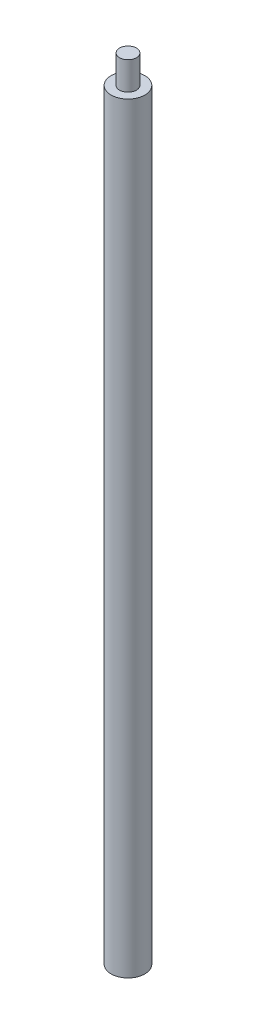
from build123d import *

# Parameters (mm, degrees)
ESBO_O1_R                     = 3
RESSALTO_EXTRUS_O1_DEPTH      = 135.5
FURO_ROSCADO_DE_M3X0_51_D     = 2.5
FURO_ROSCADO_DE_M3X0_51_DEPTH = 18.5
FURO_ROSCADO_DE_M3X0_51_TIP   = 0.751075774
ESBO_O10_R                    = 1.5
RESSALTO_EXTRUS_O2_DEPTH      = 5


with BuildPart() as part:
    # Esboço1 → Ressalto-extrusão1 (new body)
    with BuildSketch(Plane(origin=(0, 0, 0), x_dir=(1, 0, 0), z_dir=(0, 1, 0))):
        Circle(ESBO_O1_R)
    extrude(amount=RESSALTO_EXTRUS_O1_DEPTH)

    # Furo roscado de M3x0.51
    with Locations(Plane.XZ):
        with Locations((0, 0)):
            Hole(FURO_ROSCADO_DE_M3X0_51_D / 2, depth=FURO_ROSCADO_DE_M3X0_51_DEPTH)
            with Locations((0, 0, -(FURO_ROSCADO_DE_M3X0_51_DEPTH + FURO_ROSCADO_DE_M3X0_51_TIP / 2))):  # 118° drill point
                Cone(0, FURO_ROSCADO_DE_M3X0_51_D / 2, FURO_ROSCADO_DE_M3X0_51_TIP, mode=Mode.SUBTRACT)

    # Esboço10 → Ressalto-extrusão2 (add)
    with BuildSketch(Plane(origin=(0, 135.5, 0), x_dir=(1, 0, 0), z_dir=(0, 1, 0))):
        Circle(ESBO_O10_R)
    extrude(amount=RESSALTO_EXTRUS_O2_DEPTH)


solid = part.part
